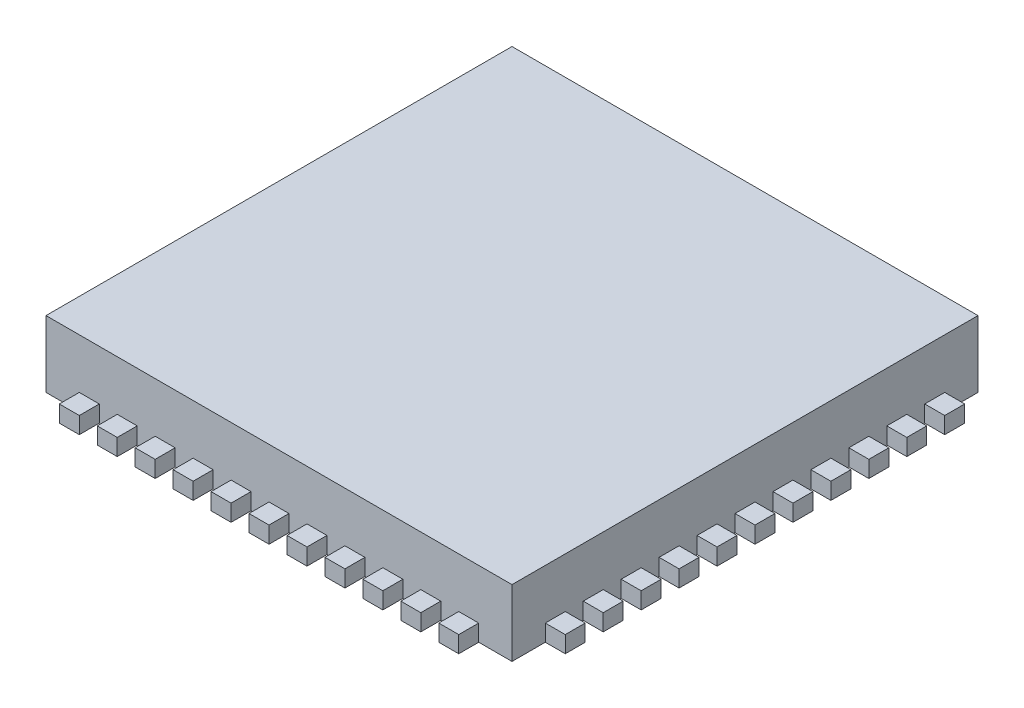
from build123d import *

# Parameters (mm, degrees)
SKETCH1_W           = 7
SKETCH1_H           = 7
BOSS_EXTRUDE1_DEPTH = 1
SKETCH2_W           = 0.3
SKETCH2_H           = 0.25
BOSS_EXTRUDE2_DEPTH = 0.3
SKETCH3_W           = 0.3
SKETCH3_H           = 0.25
BOSS_EXTRUDE3_DEPTH = 0.3
SKETCH4_W           = 0.3
SKETCH4_H           = 0.25
BOSS_EXTRUDE4_DEPTH = 0.3
SKETCH5_W           = 0.3
SKETCH5_H           = 0.25
BOSS_EXTRUDE5_DEPTH = 0.3


with BuildPart() as part:
    # Sketch1 → Boss-Extrude1 (new body)
    with BuildSketch(Plane(origin=(0, 0, 0), x_dir=(1, 0, 0), z_dir=(0, 1, 0))):
        with Locations((3.5, 3.5)):
            Rectangle(SKETCH1_W, SKETCH1_H)
    extrude(amount=BOSS_EXTRUDE1_DEPTH)

    # Sketch2 → Boss-Extrude2 (add)
    with BuildSketch(Plane.XY):
        with Locations((0.65, 0.125)):
            Rectangle(SKETCH2_W, SKETCH2_H)
        with Locations((1.22, 0.125)):
            Rectangle(SKETCH2_W, SKETCH2_H)
        with Locations((1.79, 0.125)):
            Rectangle(SKETCH2_W, SKETCH2_H)
        with Locations((2.36, 0.125)):
            Rectangle(SKETCH2_W, SKETCH2_H)
        with Locations((2.93, 0.125)):
            Rectangle(SKETCH2_W, SKETCH2_H)
        with Locations((3.5, 0.125)):
            Rectangle(SKETCH2_W, SKETCH2_H)
        with Locations((4.07, 0.125)):
            Rectangle(SKETCH2_W, SKETCH2_H)
        with Locations((4.64, 0.125)):
            Rectangle(SKETCH2_W, SKETCH2_H)
        with Locations((5.21, 0.125)):
            Rectangle(SKETCH2_W, SKETCH2_H)
        with Locations((5.78, 0.125)):
            Rectangle(SKETCH2_W, SKETCH2_H)
        with Locations((6.35, 0.125)):
            Rectangle(SKETCH2_W, SKETCH2_H)
    extrude(amount=BOSS_EXTRUDE2_DEPTH)

    # Sketch3 → Boss-Extrude3 (add)
    with BuildSketch(Plane(origin=(7, 0, 0), x_dir=(0, 0, -1), z_dir=(1, 0, 0))):
        with Locations((0.65, 0.125)):
            Rectangle(SKETCH3_W, SKETCH3_H)
        with Locations((1.22, 0.125)):
            Rectangle(SKETCH3_W, SKETCH3_H)
        with Locations((1.79, 0.125)):
            Rectangle(SKETCH3_W, SKETCH3_H)
        with Locations((2.36, 0.125)):
            Rectangle(SKETCH3_W, SKETCH3_H)
        with Locations((2.93, 0.125)):
            Rectangle(SKETCH3_W, SKETCH3_H)
        with Locations((3.5, 0.125)):
            Rectangle(SKETCH3_W, SKETCH3_H)
        with Locations((4.07, 0.125)):
            Rectangle(SKETCH3_W, SKETCH3_H)
        with Locations((4.64, 0.125)):
            Rectangle(SKETCH3_W, SKETCH3_H)
        with Locations((5.21, 0.125)):
            Rectangle(SKETCH3_W, SKETCH3_H)
        with Locations((5.78, 0.125)):
            Rectangle(SKETCH3_W, SKETCH3_H)
        with Locations((6.35, 0.125)):
            Rectangle(SKETCH3_W, SKETCH3_H)
    extrude(amount=BOSS_EXTRUDE3_DEPTH)

    # Sketch4 → Boss-Extrude4 (add)
    with BuildSketch(Plane(origin=(0, 0, -7), x_dir=(-1, 0, 0), z_dir=(0, 0, -1))):
        with Locations((-6.35, 0.125)):
            Rectangle(SKETCH4_W, SKETCH4_H)
        with Locations((-5.78, 0.125)):
            Rectangle(SKETCH4_W, SKETCH4_H)
        with Locations((-5.21, 0.125)):
            Rectangle(SKETCH4_W, SKETCH4_H)
        with Locations((-4.64, 0.125)):
            Rectangle(SKETCH4_W, SKETCH4_H)
        with Locations((-4.07, 0.125)):
            Rectangle(SKETCH4_W, SKETCH4_H)
        with Locations((-3.5, 0.125)):
            Rectangle(SKETCH4_W, SKETCH4_H)
        with Locations((-2.93, 0.125)):
            Rectangle(SKETCH4_W, SKETCH4_H)
        with Locations((-2.36, 0.125)):
            Rectangle(SKETCH4_W, SKETCH4_H)
        with Locations((-1.79, 0.125)):
            Rectangle(SKETCH4_W, SKETCH4_H)
        with Locations((-1.22, 0.125)):
            Rectangle(SKETCH4_W, SKETCH4_H)
        with Locations((-0.65, 0.125)):
            Rectangle(SKETCH4_W, SKETCH4_H)
    extrude(amount=BOSS_EXTRUDE4_DEPTH)

    # Sketch5 → Boss-Extrude5 (add)
    with BuildSketch(Plane.ZY):
        with Locations((-6.35, 0.125)):
            Rectangle(SKETCH5_W, SKETCH5_H)
        with Locations((-5.78, 0.125)):
            Rectangle(SKETCH5_W, SKETCH5_H)
        with Locations((-5.21, 0.125)):
            Rectangle(SKETCH5_W, SKETCH5_H)
        with Locations((-4.64, 0.125)):
            Rectangle(SKETCH5_W, SKETCH5_H)
        with Locations((-4.07, 0.125)):
            Rectangle(SKETCH5_W, SKETCH5_H)
        with Locations((-3.5, 0.125)):
            Rectangle(SKETCH5_W, SKETCH5_H)
        with Locations((-2.93, 0.125)):
            Rectangle(SKETCH5_W, SKETCH5_H)
        with Locations((-2.36, 0.125)):
            Rectangle(SKETCH5_W, SKETCH5_H)
        with Locations((-1.79, 0.125)):
            Rectangle(SKETCH5_W, SKETCH5_H)
        with Locations((-1.22, 0.125)):
            Rectangle(SKETCH5_W, SKETCH5_H)
        with Locations((-0.65, 0.125)):
            Rectangle(SKETCH5_W, SKETCH5_H)
    extrude(amount=BOSS_EXTRUDE5_DEPTH)


solid = part.part
